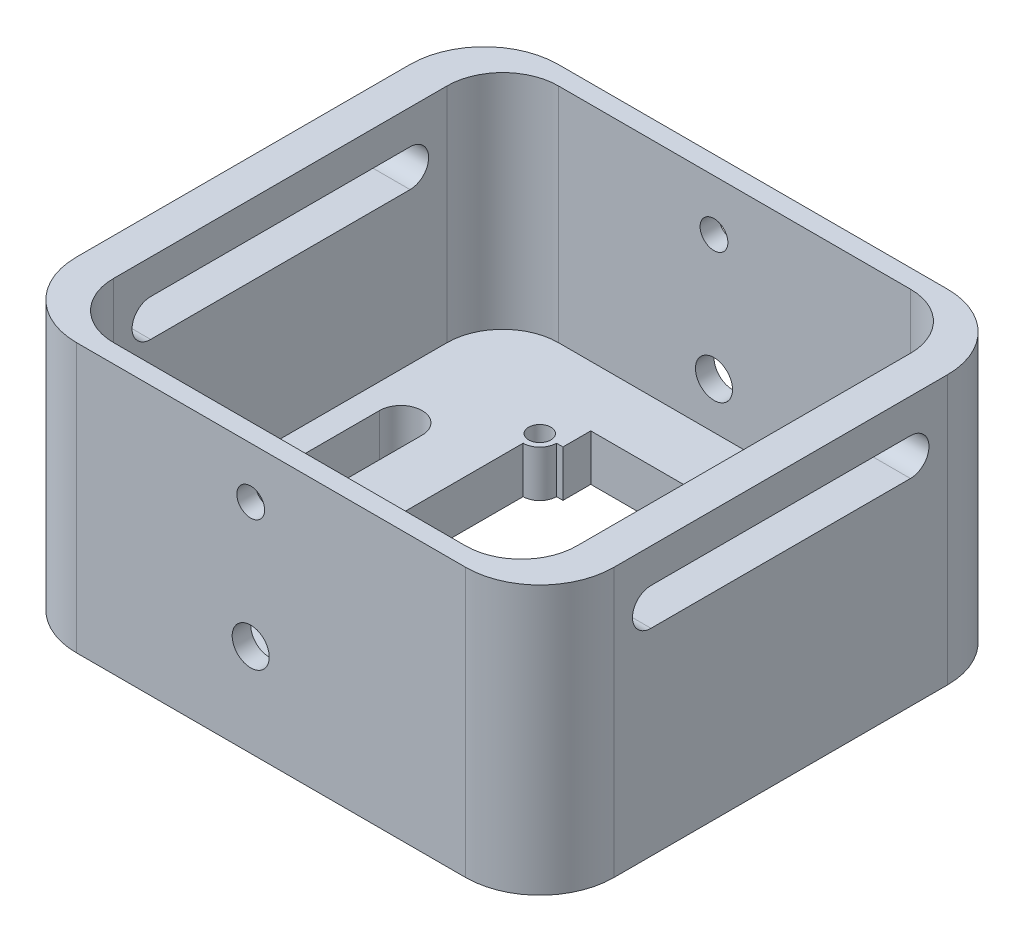
from build123d import *

# Parameters (mm, degrees)
SKETCH1_W                = 25
SKETCH1_H                = 24
SKETCH1_R                = 0.6
BOSS_EXTRUDE1_DEPTH      = 2.5
CUT_EXTRUDE1_DEPTH       = 3.5
SKETCH8_W                = 11
SKETCH8_H                = 17.5
CUT_EXTRUDE4_DEPTH       = 3.5
SKETCH2_W                = 29
SKETCH2_H                = 26
SKETCH2_W_2              = 25
SKETCH2_H_2              = 24
BOSS_EXTRUDE2_DEPTH      = 12
BOSS_EXTRUDE2_DEPTH_BACK = 2.5
SKETCH5_R                = 0.75
SKETCH5_R_2              = 1
CUT_EXTRUDE2_DEPTH       = 26
CUT_EXTRUDE2_DEPTH_BACK  = 2
FILLET1_R                = 3
FILLET2_R                = 4
CUT_EXTRUDE5_DEPTH       = 30


with BuildPart() as part:
    # Sketch1 → Boss-Extrude1 (new body)
    with BuildSketch(Plane(origin=(0, 0, 0), x_dir=(1, 0, 0), z_dir=(0, 1, 0))):
        Rectangle(SKETCH1_W, SKETCH1_H)
        with Locations((7.75, 7.25)):
            Circle(SKETCH1_R, mode=Mode.SUBTRACT)
        with Locations((7.75, -7.25)):
            Circle(SKETCH1_R, mode=Mode.SUBTRACT)
        with Locations((-5.75, -7.25)):
            Circle(SKETCH1_R, mode=Mode.SUBTRACT)
        with Locations((-5.75, 7.25)):
            Circle(SKETCH1_R, mode=Mode.SUBTRACT)
        with BuildLine():
            Line((8.85, -4), (8.85, 4))
            ThreePointArc((8.85, 4), (10, 5.15), (11.15, 4))
            Line((11.15, 4), (11.15, -4))
            ThreePointArc((11.15, -4), (10, -5.15), (8.85, -4))
        make_face(mode=Mode.SUBTRACT)
        with BuildLine():
            Line((-8.85, -4), (-8.85, 4))
            ThreePointArc((-8.85, 4), (-10, 5.15), (-11.15, 4))
            Line((-11.15, 4), (-11.15, -4))
            ThreePointArc((-11.15, -4), (-10, -5.15), (-8.85, -4))
        make_face(mode=Mode.SUBTRACT)
    extrude(amount=BOSS_EXTRUDE1_DEPTH)

    # Sketch3 → Cut-Extrude1 (cut, through all)
    with BuildSketch(Plane(origin=(0, 2.5, 0), x_dir=(1, 0, 0), z_dir=(0, 1, 0))):
        with BuildLine():
            Line((-4.85, 7.25), (6.85, 7.25))
            ThreePointArc((6.85, 7.25), (7.113603897, 6.613603897), (7.75, 6.35))
            Line((7.75, 6.35), (7.75, -6.35))
            ThreePointArc((7.75, -6.35), (7.113603897, -6.613603897), (6.85, -7.25))
            Line((6.85, -7.25), (-4.85, -7.25))
            ThreePointArc((-4.85, -7.25), (-5.113603897, -6.613603897), (-5.75, -6.35))
            Line((-5.75, -6.35), (-5.75, 6.35))
            ThreePointArc((-5.75, 6.35), (-5.113603897, 6.613603897), (-4.85, 7.25))
        make_face()
    extrude(amount=-CUT_EXTRUDE1_DEPTH, mode=Mode.SUBTRACT)

    # Sketch8 → Cut-Extrude4 (cut, through all)
    with BuildSketch(Plane(origin=(0, 2.5, 0), x_dir=(1, 0, 0), z_dir=(0, 1, 0))):
        with Locations((1, 0)):
            Rectangle(SKETCH8_W, SKETCH8_H)
    extrude(amount=-CUT_EXTRUDE4_DEPTH, mode=Mode.SUBTRACT)

    # Sketch2 → Boss-Extrude2 (add, two sides)
    with BuildSketch(Plane(origin=(0, 2.5, 0), x_dir=(1, 0, 0), z_dir=(0, 1, 0))) as boss_extrude2_sk:
        Rectangle(SKETCH2_W, SKETCH2_H)
        Rectangle(SKETCH2_W_2, SKETCH2_H_2, mode=Mode.SUBTRACT)
    extrude(amount=BOSS_EXTRUDE2_DEPTH)
    extrude(boss_extrude2_sk.sketch, amount=-BOSS_EXTRUDE2_DEPTH_BACK)

    # Sketch5 → Cut-Extrude2 (cut, two sides)
    with BuildSketch(Plane.XY.offset(-12)) as cut_extrude2_sk:
        with Locations((-1.1, 11.75)):
            Circle(SKETCH5_R)
        with Locations((-1.1, 5)):
            Circle(SKETCH5_R_2)
    extrude(amount=CUT_EXTRUDE2_DEPTH, mode=Mode.SUBTRACT)
    extrude(cut_extrude2_sk.sketch, amount=-CUT_EXTRUDE2_DEPTH_BACK, mode=Mode.SUBTRACT)

    # Fillet1
    fillet1_edges = [part.edges().sort_by_distance(p)[0] for p in [
        (12.5, 8.5, 12),
        (-12.5, 8.5, -12),
        (12.5, 8.5, -12),
        (-12.5, 8.5, 12),
    ]]
    fillet(fillet1_edges, radius=FILLET1_R)

    # Fillet2
    fillet2_edges = [part.edges().sort_by_distance(p)[0] for p in [
        (-14.5, 7.25, 13),
        (14.5, 7.25, 13),
        (14.5, 7.25, -13),
        (-14.5, 7.25, -13),
    ]]
    fillet(fillet2_edges, radius=FILLET2_R)

    # Sketch9 → Cut-Extrude5 (cut, through all)
    with BuildSketch(Plane(origin=(14.5, 0, 0), x_dir=(0, 0, -1), z_dir=(1, 0, 0))):
        with BuildLine():
            Line((-7, 12.65), (7, 12.65))
            ThreePointArc((7, 12.65), (8, 11.65), (7, 10.65))
            Line((7, 10.65), (-7, 10.65))
            ThreePointArc((-7, 10.65), (-8, 11.65), (-7, 12.65))
        make_face()
    extrude(amount=-CUT_EXTRUDE5_DEPTH, mode=Mode.SUBTRACT)


solid = part.part
